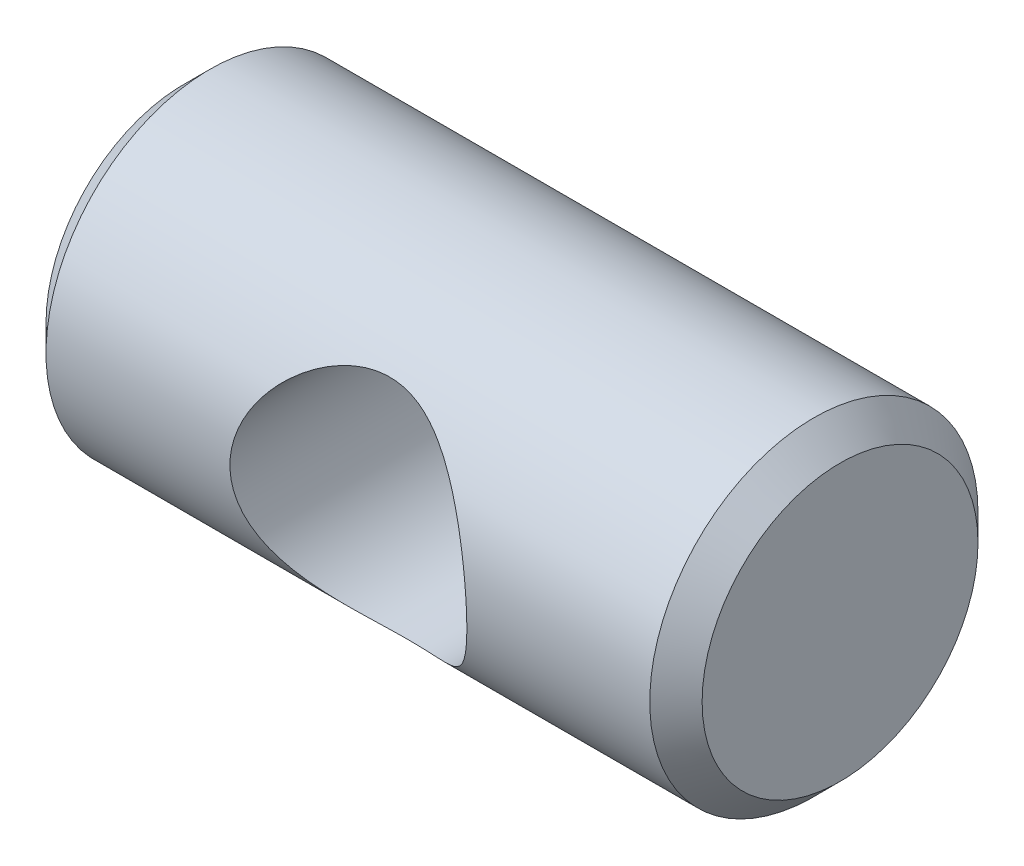
from build123d import *

# Parameters (mm, degrees)
ESQUISSE1_R             = 4.765
BOSS_EXTRU_1_DEPTH      = 9.525
CHANFREIN1_SIZE         = 0.76
ESQUISSE2_R             = 3.43
ENL_V_MAT_EXTRU_1_DEPTH = 9.525


with BuildPart() as part:
    # Esquisse1 → Boss.-Extru.1 (new body, symmetric)
    with BuildSketch(Plane(origin=(0, 0, 0), x_dir=(0, 0, -1), z_dir=(1, 0, 0))):
        Circle(ESQUISSE1_R)
    extrude(amount=BOSS_EXTRU_1_DEPTH, both=True)

    # Chanfrein1
    chanfrein1_edges = [part.edges().sort_by_distance(p)[0] for p in [
        (-9.525, 0, 4.765),
        (9.525, 0, 4.765),
    ]]
    chamfer(chanfrein1_edges, length=CHANFREIN1_SIZE)

    # Esquisse2 → Enlèv. mat.-Extru.1 (cut, symmetric)
    with BuildSketch(Plane.XY):
        with Locations((0, -0.25)):
            Circle(ESQUISSE2_R)
    extrude(amount=ENL_V_MAT_EXTRU_1_DEPTH, both=True, mode=Mode.SUBTRACT)


solid = part.part
